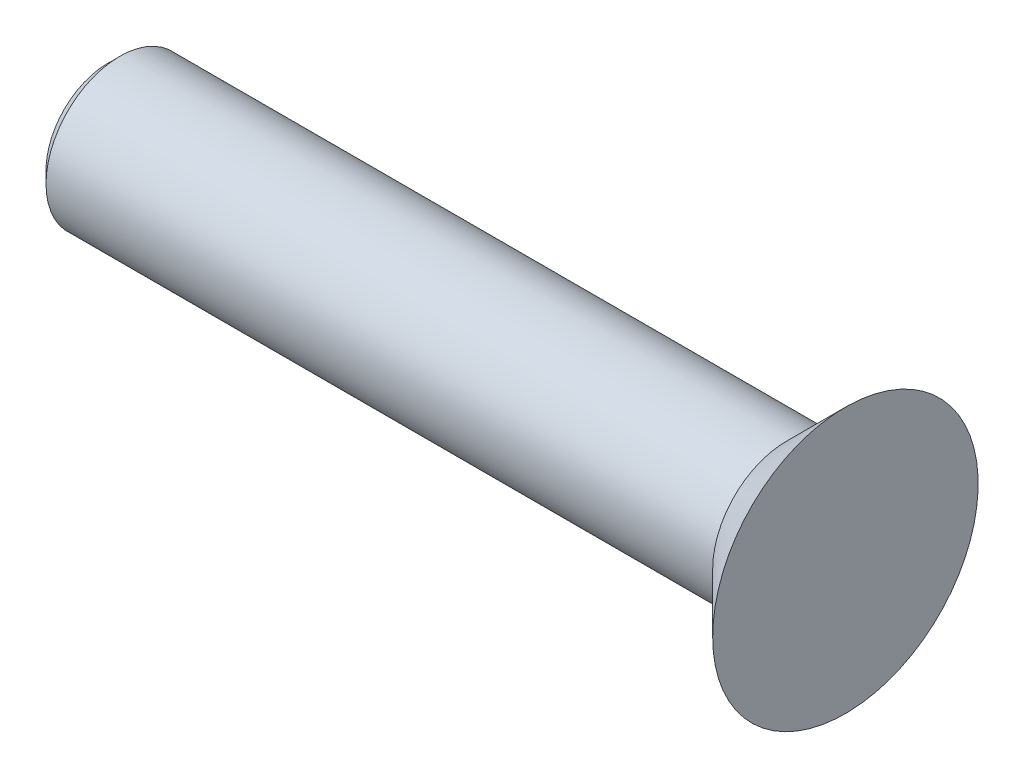
from build123d import *

# Parameters (mm, degrees)
CHANFREIN1_SIZE = 0.4


with BuildPart() as part:
    # Esquisse1 → Révolution1 (revolve)
    with BuildSketch(Plane.XY, mode=Mode.PRIVATE) as r_volution1_sk:
        Polygon((0, 0), (-25, 0), (-25, 2.5), (-2, 2.5), (0, 4.5), align=None)
    revolve(r_volution1_sk.sketch.rotate(Axis((0, 0, 0), (1, 0, 0)), 90), axis=Axis((0, 0, 0), (1, 0, 0)))  # turned: the seam where the file's is

    # Chanfrein1
    chanfrein1_edges = [part.edges().sort_by_distance(p)[0] for p in [
        (-25, 0, -2.5),
    ]]
    chamfer(chanfrein1_edges, length=CHANFREIN1_SIZE)


solid = part.part
